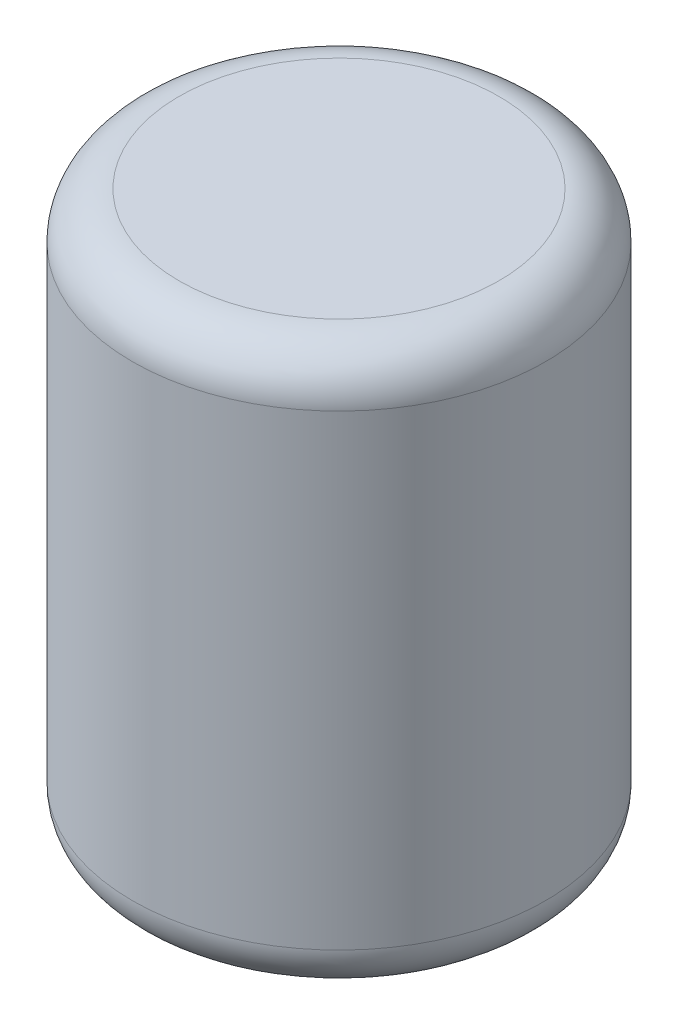
from build123d import *

# Parameters (mm, degrees)
SKETCH2_R           = 44.25
BOSS_EXTRUDE1_DEPTH = 120
FILLET1_R           = 10


with BuildPart() as part:
    # Sketch2 → Boss-Extrude1 (new body)
    with BuildSketch(Plane(origin=(0, 0, 0), x_dir=(1, 0, 0), z_dir=(0, 1, 0))):
        Circle(SKETCH2_R)
    extrude(amount=BOSS_EXTRUDE1_DEPTH)

    # Fillet1
    fillet1_edges = [part.edges().sort_by_distance(p)[0] for p in [
        (-44.25, 0, 0),
        (-44.25, 120, 0),
    ]]
    fillet(fillet1_edges, radius=FILLET1_R)


solid = part.part
